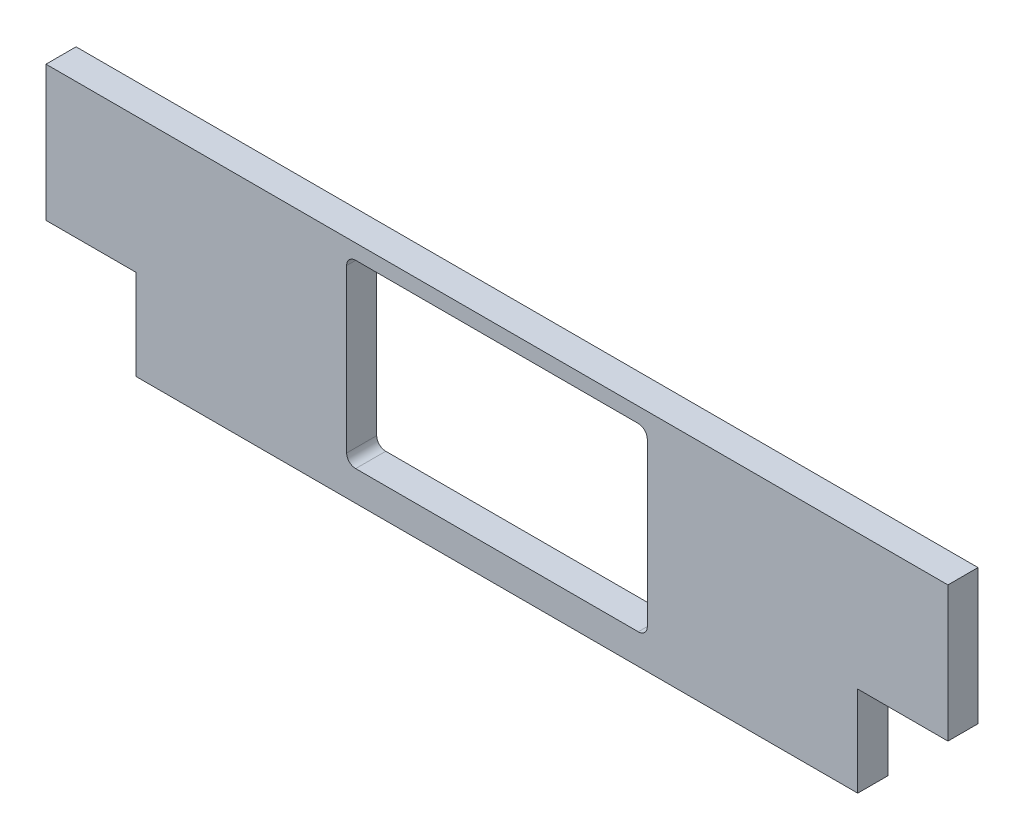
from build123d import *

# Parameters (mm, degrees)
SKIZZE1_W                       = 300
SKIZZE1_H                       = 75
LINEAR_AUSTRAGEN1_DEPTH         = 10
SKIZZE2_W                       = 100
SKIZZE2_H                       = 60
SCHNITT_LINEAR_AUSTRAGEN1_DEPTH = 10
VERRUNDUNG1_R                   = 3
SKIZZE4_W                       = 10
SKIZZE4_H                       = 30
SCHNITT_LINEAR_AUSTRAGEN2_DEPTH = 30


with BuildPart() as part:
    # Skizze1 → Linear austragen1 (new body)
    with BuildSketch(Plane.XY):
        with Locations((0, -112.5)):
            Rectangle(SKIZZE1_W, SKIZZE1_H)
    extrude(amount=LINEAR_AUSTRAGEN1_DEPTH)

    # Skizze2 → Schnitt-Linear austragen1 (cut)
    with BuildSketch(Plane.XY.offset(10)):
        with Locations((0, -110)):
            Rectangle(SKIZZE2_W, SKIZZE2_H)
    extrude(amount=-SCHNITT_LINEAR_AUSTRAGEN1_DEPTH, mode=Mode.SUBTRACT)

    # Verrundung1
    verrundung1_edges = [part.edges().sort_by_distance(p)[0] for p in [
        (50, -80, 5),
        (50, -140, 5),
        (-50, -140, 5),
        (-50, -80, 5),
    ]]
    fillet(verrundung1_edges, radius=VERRUNDUNG1_R)

    # Skizze4 → Schnitt-Linear austragen2 (cut)
    with BuildSketch(Plane(origin=(150, 0, 0), x_dir=(0, 0, -1), z_dir=(1, 0, 0))):
        with Locations((-5, -135)):
            Rectangle(SKIZZE4_W, SKIZZE4_H)
    schnitt_linear_austragen2 = extrude(amount=-SCHNITT_LINEAR_AUSTRAGEN2_DEPTH, mode=Mode.SUBTRACT)

    # Spiegeln1: Schnitt-Linear austragen2 across plane
    add(schnitt_linear_austragen2.mirror(Plane(origin=(0, 0, 0), x_dir=(0, 0, 1), z_dir=(1, 0, 0))), mode=Mode.SUBTRACT)


solid = part.part
